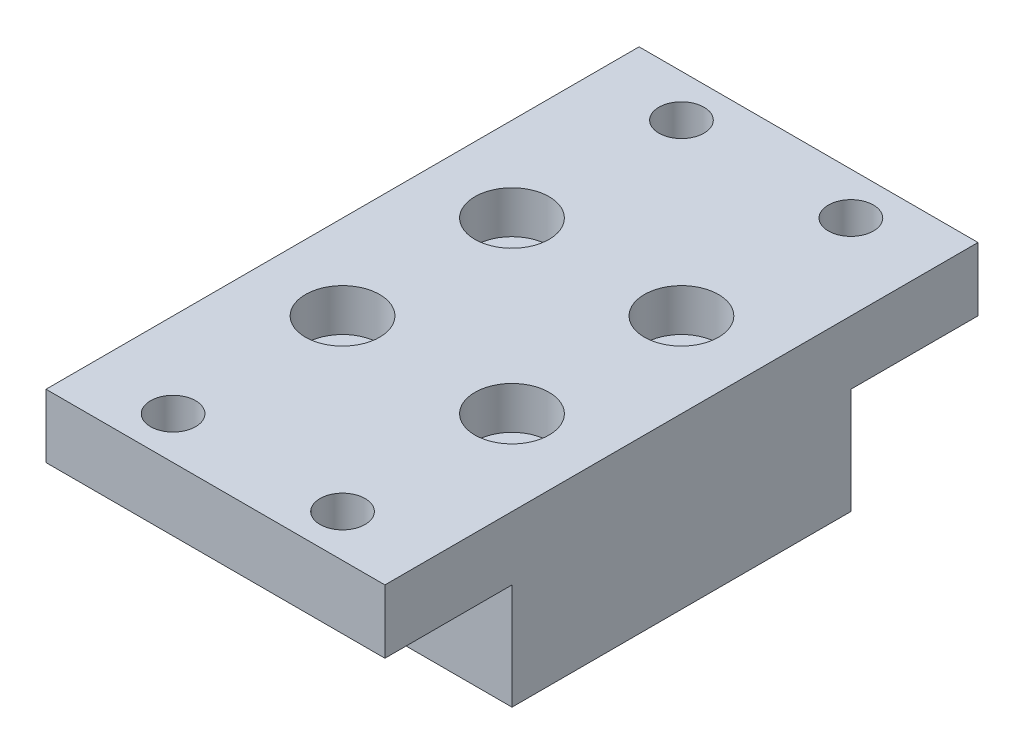
from build123d import *

# Parameters (mm, degrees)
SKETCH1_W                                        = 50.8
SKETCH1_H                                        = 50.8
BOSS_EXTRUDE1_DEPTH                              = 25.4
SKETCH7_W                                        = 50.8
SKETCH7_H                                        = 9.525
BOSS_EXTRUDE2_DEPTH                              = 19.05
SKETCH11_W                                       = 50.8
SKETCH11_H                                       = 9.525
BOSS_EXTRUDE3_DEPTH                              = 19.05
F_1_4_CLEARANCE_HOLE1_D                          = 6.7564
CBORE_FOR_1_4_SOCKET_HEAD_CAP_SCREW1_D           = 6.7564
CBORE_FOR_1_4_SOCKET_HEAD_CAP_SCREW1_CBORE_D     = 11.1125
CBORE_FOR_1_4_SOCKET_HEAD_CAP_SCREW1_CBORE_DEPTH = 6.35
LPATTERN1_COUNT                                  = 4
LPATTERN1_PITCH                                  = 25.4
LPATTERN1_COUNT_DIR2                             = 2
LPATTERN1_PITCH_DIR2                             = 25.4
LPATTERN2_COUNT                                  = 2
LPATTERN2_PITCH                                  = 25.4
LPATTERN2_COUNT_DIR2                             = 2
LPATTERN2_PITCH_DIR2                             = 25.4


with BuildPart() as part:
    # Sketch1 → Boss-Extrude1 (new body)
    with BuildSketch(Plane(origin=(0, 0, 0), x_dir=(1, 0, 0), z_dir=(0, 1, 0))):
        with Locations((25.4, 25.4)):
            Rectangle(SKETCH1_W, SKETCH1_H)
    extrude(amount=BOSS_EXTRUDE1_DEPTH)

    # Sketch7 → Boss-Extrude2 (add)
    with BuildSketch(Plane(origin=(0, 0, -50.8), x_dir=(-1, 0, 0), z_dir=(0, 0, -1))):
        with Locations((-25.4, 20.6375)):
            Rectangle(SKETCH7_W, SKETCH7_H)
    extrude(amount=BOSS_EXTRUDE2_DEPTH)

    # Sketch11 → Boss-Extrude3 (add)
    with BuildSketch(Plane.XY):
        with Locations((25.4, 20.6375)):
            Rectangle(SKETCH11_W, SKETCH11_H)
    extrude(amount=BOSS_EXTRUDE3_DEPTH)

    # 1/4 Clearance Hole1 (through all)
    with Locations(Plane(origin=(0, 25.4, 0), x_dir=(-1, 0, 0), z_dir=(0, 1, 0))):
        with Locations((-12.7, -63.5)):
            f_1_4_clearance_hole1 = Hole(F_1_4_CLEARANCE_HOLE1_D / 2)

    # CBORE for 1/4 Socket Head Cap Screw1 (through all)
    with Locations(Plane(origin=(0, 25.4, 0), x_dir=(-1, 0, 0), z_dir=(0, 1, 0))):
        with Locations((-12.7, -12.7)):
            cbore_for_1_4_socket_head_cap_screw1 = CounterBoreHole(CBORE_FOR_1_4_SOCKET_HEAD_CAP_SCREW1_D / 2, CBORE_FOR_1_4_SOCKET_HEAD_CAP_SCREW1_CBORE_D / 2, CBORE_FOR_1_4_SOCKET_HEAD_CAP_SCREW1_CBORE_DEPTH)

    # LPattern1: 1_4 Clearance Hole1 4 × 2
    with Locations(*[(j * LPATTERN1_PITCH_DIR2, 0, i * LPATTERN1_PITCH) for i in range(LPATTERN1_COUNT) for j in range(LPATTERN1_COUNT_DIR2) if (i, j) != (0, 0)]):
        add(f_1_4_clearance_hole1, mode=Mode.SUBTRACT)

    # LPattern2: CBORE for 1_4 Socket Head Cap Screw1 2 × 2
    with Locations(*[(j * LPATTERN2_PITCH_DIR2, 0, -i * LPATTERN2_PITCH) for i in range(LPATTERN2_COUNT) for j in range(LPATTERN2_COUNT_DIR2) if (i, j) != (0, 0)]):
        add(cbore_for_1_4_socket_head_cap_screw1, mode=Mode.SUBTRACT)


solid = part.part
